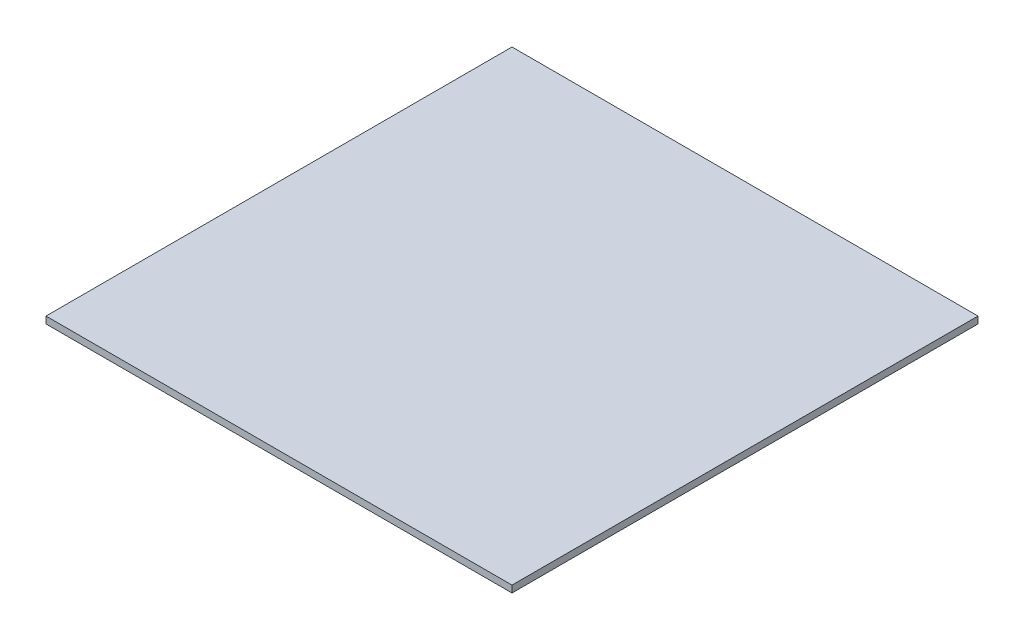
from build123d import *

# Parameters (mm, degrees)
SKETCH1_W           = 215.41
SKETCH1_H           = 215.41
BOSS_EXTRUDE1_DEPTH = 3.175


with BuildPart() as part:
    # Sketch1 → Boss-Extrude1 (new body)
    with BuildSketch(Plane(origin=(0, 0, 0), x_dir=(1, 0, 0), z_dir=(0, 1, 0))):
        Rectangle(SKETCH1_W, SKETCH1_H)
    extrude(amount=BOSS_EXTRUDE1_DEPTH)


solid = part.part
